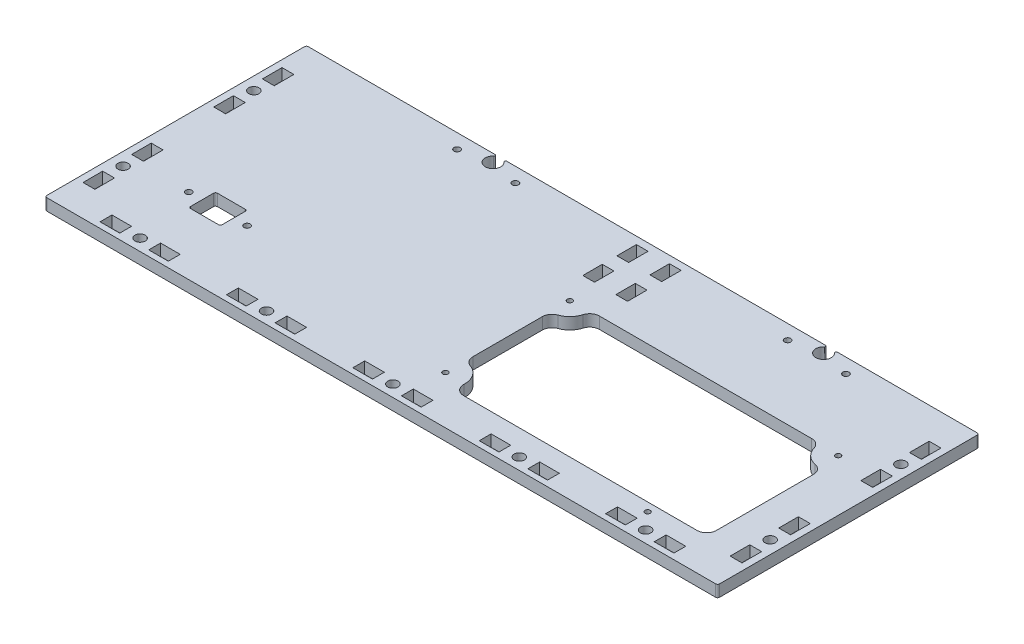
from build123d import *

# Parameters (mm, degrees)
SKETCH1_W                = 346
SKETCH1_H                = 134.5
BOSS_EXTRUDE1_DEPTH      = 6
M5_CLEARANCE_HOLE1_D     = 5.3
M5_CLEARANCE_HOLE2_D     = 5.3
SKETCH5_W                = 140
SKETCH5_H                = 70.4
CUT_EXTRUDE1_DEPTH       = 7
SKETCH6_R                = 10
BOSS_EXTRUDE2_DEPTH      = 6
FILLET1_R                = 5
M2_5_CLEARANCE_HOLE1_D   = 2.7
CUT_EXTRUDE29_DEPTH      = 7
SKETCH72_W               = 6.1
SKETCH72_H               = 10.1
CUT_EXTRUDE2_DEPTH       = 4
CUT_EXTRUDE2_DEPTH_BACK  = 4
SKETCH73_W               = 6.1
SKETCH73_H               = 10.1
CUT_EXTRUDE21_DEPTH      = 4
CUT_EXTRUDE21_DEPTH_BACK = 4
SKETCH74_W               = 6.1
SKETCH74_H               = 10.1
CUT_EXTRUDE22_DEPTH      = 4
CUT_EXTRUDE22_DEPTH_BACK = 4
SKETCH75_W               = 6.1
SKETCH75_H               = 10.1
CUT_EXTRUDE23_DEPTH      = 4
CUT_EXTRUDE23_DEPTH_BACK = 4
SKETCH76_W               = 6.1
SKETCH76_H               = 10.1
CUT_EXTRUDE24_DEPTH      = 4
CUT_EXTRUDE24_DEPTH_BACK = 4
SKETCH771_W              = 6.1
SKETCH771_H              = 10.1
CUT_EXTRUDE25_DEPTH      = 4
CUT_EXTRUDE25_DEPTH_BACK = 4
SKETCH781_W              = 6.1
SKETCH781_H              = 10.1
CUT_EXTRUDE26_DEPTH      = 4
CUT_EXTRUDE26_DEPTH_BACK = 4
SKETCH79_W               = 6.1
SKETCH79_H               = 10.1
CUT_EXTRUDE27_DEPTH      = 4
CUT_EXTRUDE27_DEPTH_BACK = 4
SKETCH710_W              = 6.1
SKETCH710_H              = 10.1
CUT_EXTRUDE28_DEPTH      = 4
CUT_EXTRUDE28_DEPTH_BACK = 4
SKETCH63_W               = 10
SKETCH63_H               = 6
CUT_EXTRUDE13_DEPTH      = 4
SKETCH64_W               = 10
SKETCH64_H               = 6
CUT_EXTRUDE14_DEPTH      = 4
M3_CLEARANCE_HOLE1_D     = 3.2
SKETCH786_W              = 16.25
SKETCH786_H              = 13.75
CUT_EXTRUDE30_DEPTH      = 7
M3_CLEARANCE_HOLE2_D     = 3.2
FILLET2_R                = 1
FILLET3_R                = 1


with BuildPart() as part:
    # Sketch1 → Boss-Extrude1 (new body)
    with BuildSketch(Plane(origin=(0, 0, 0), x_dir=(1, 0, 0), z_dir=(0, 1, 0))):
        Rectangle(SKETCH1_W, SKETCH1_H)
    extrude(amount=BOSS_EXTRUDE1_DEPTH)

    # M5 Clearance Hole1 (through all)
    with Locations(Plane(origin=(0, 6, 0), x_dir=(1, 0, 0), z_dir=(0, 1, 0))):
        with Locations((0, -61.25), (65, -61.25), (130, -61.25)):
            m5_clearance_hole1 = Hole(M5_CLEARANCE_HOLE1_D / 2)

    # Mirror1: M5 Clearance Hole1 across plane
    add(m5_clearance_hole1.mirror(Plane(origin=(0, 0, 0), x_dir=(0, 0, 1), z_dir=(1, 0, 0))), mode=Mode.SUBTRACT)

    # M5 Clearance Hole2 (through all)
    with Locations(Plane(origin=(0, 6, 0), x_dir=(1, 0, 0), z_dir=(0, 1, 0))):
        with Locations((166.4, -33.625), (166.4, 33.625)):
            m5_clearance_hole2 = Hole(M5_CLEARANCE_HOLE2_D / 2)

    # Mirror2: M5 Clearance Hole2 across plane
    add(m5_clearance_hole2.mirror(Plane(origin=(0, 0, 0), x_dir=(0, 0, 1), z_dir=(1, 0, 0))), mode=Mode.SUBTRACT)

    # Sketch5 → Cut-Extrude1 (cut, through all)
    with BuildSketch(Plane(origin=(0, 0, 0), x_dir=(-1, 0, 0), z_dir=(0, -1, 0))):
        with Locations((-78.4, -13.05)):
            Rectangle(SKETCH5_W, SKETCH5_H)
    extrude(amount=-CUT_EXTRUDE1_DEPTH, mode=Mode.SUBTRACT)

    # Sketch6 → Boss-Extrude2 (add)
    with BuildSketch(Plane.XZ):
        with Locations((8.4, -21.35)):
            Circle(SKETCH6_R)
        with Locations((8.4, 42.65)):
            Circle(SKETCH6_R)
        with Locations((146.4, -21.35)):
            Circle(SKETCH6_R)
    extrude(amount=-BOSS_EXTRUDE2_DEPTH)

    # Fillet1
    fillet1_edges = [part.edges().sort_by_distance(p)[0] for p in [
        (148.4, 3, -11.552041029),
        (148.4, 3, 48.25),
        (8.4, 3, -11.35),
        (18.367948636, 3, -22.15),
        (16.684926071, 3, 48.25),
        (8.4, 3, 32.65),
        (136.432051364, 3, -22.15),
    ]]
    fillet(fillet1_edges, radius=FILLET1_R)

    # M2.5 Clearance Hole1 (through all)
    with Locations(Plane(origin=(0, 6, 0), x_dir=(1, 0, 0), z_dir=(0, 1, 0))):
        with Locations((8.4, -42.65), (8.4, 21.35), (146.4, 21.35), (122.4, -52.65)):
            Hole(M2_5_CLEARANCE_HOLE1_D / 2)

    # Sketch783 → Cut-Extrude29 (cut, through all)
    with BuildSketch(Plane(origin=(0, 6, 0), x_dir=(1, 0, 0), z_dir=(0, 1, 0))):
        with BuildLine():
            Line((-76.023715784, 67.25), (-69.976284216, 67.25))
            ThreePointArc((-69.976284216, 67.25), (-70.5108067, 66.880601937), (-70.354248689, 66.25))
            ThreePointArc((-70.354248689, 66.25), (-73, 59.25), (-75.645751311, 66.25))
            ThreePointArc((-75.645751311, 66.25), (-75.4891933, 66.880601937), (-76.023715784, 67.25))
        make_face()
    cut_extrude29 = extrude(amount=-CUT_EXTRUDE29_DEPTH, mode=Mode.SUBTRACT)

    # Mirror4: Cut-Extrude29 across plane
    add(cut_extrude29.mirror(Plane.ZY.offset(-12)), mode=Mode.SUBTRACT)

    # Sketch72 → Cut-Extrude2 (cut, two sides)
    with BuildSketch(Plane(origin=(110, 3, 105.25), x_dir=(0, 0, -1), z_dir=(0, 1, 0))) as cut_extrude2_sk:
        with Locations((44, -32.5)):
            Rectangle(SKETCH72_W, SKETCH72_H)
        with Locations((44, -7.5)):
            Rectangle(SKETCH72_W, SKETCH72_H)
    extrude(amount=CUT_EXTRUDE2_DEPTH, mode=Mode.SUBTRACT)
    extrude(cut_extrude2_sk.sketch, amount=-CUT_EXTRUDE2_DEPTH_BACK, mode=Mode.SUBTRACT)

    # Sketch73 → Cut-Extrude21 (cut, two sides)
    with BuildSketch(Plane(origin=(45, 3, 105.25), x_dir=(0, 0, -1), z_dir=(0, 1, 0))) as cut_extrude21_sk:
        with Locations((44, -32.5)):
            Rectangle(SKETCH73_W, SKETCH73_H)
        with Locations((44, -7.5)):
            Rectangle(SKETCH73_W, SKETCH73_H)
    extrude(amount=CUT_EXTRUDE21_DEPTH, mode=Mode.SUBTRACT)
    extrude(cut_extrude21_sk.sketch, amount=-CUT_EXTRUDE21_DEPTH_BACK, mode=Mode.SUBTRACT)

    # Sketch74 → Cut-Extrude22 (cut, two sides)
    with BuildSketch(Plane(origin=(-20, 3, 105.25), x_dir=(0, 0, -1), z_dir=(0, 1, 0))) as cut_extrude22_sk:
        with Locations((44, -32.5)):
            Rectangle(SKETCH74_W, SKETCH74_H)
        with Locations((44, -7.5)):
            Rectangle(SKETCH74_W, SKETCH74_H)
    extrude(amount=CUT_EXTRUDE22_DEPTH, mode=Mode.SUBTRACT)
    extrude(cut_extrude22_sk.sketch, amount=-CUT_EXTRUDE22_DEPTH_BACK, mode=Mode.SUBTRACT)

    # Sketch75 → Cut-Extrude23 (cut, two sides)
    with BuildSketch(Plane(origin=(-85, 3, 105.25), x_dir=(0, 0, -1), z_dir=(0, 1, 0))) as cut_extrude23_sk:
        with Locations((44, -32.5)):
            Rectangle(SKETCH75_W, SKETCH75_H)
        with Locations((44, -7.5)):
            Rectangle(SKETCH75_W, SKETCH75_H)
    extrude(amount=CUT_EXTRUDE23_DEPTH, mode=Mode.SUBTRACT)
    extrude(cut_extrude23_sk.sketch, amount=-CUT_EXTRUDE23_DEPTH_BACK, mode=Mode.SUBTRACT)

    # Sketch76 → Cut-Extrude24 (cut, two sides)
    with BuildSketch(Plane(origin=(-150, 3, 105.25), x_dir=(0, 0, -1), z_dir=(0, 1, 0))) as cut_extrude24_sk:
        with Locations((44, -32.5)):
            Rectangle(SKETCH76_W, SKETCH76_H)
        with Locations((44, -7.5)):
            Rectangle(SKETCH76_W, SKETCH76_H)
    extrude(amount=CUT_EXTRUDE24_DEPTH, mode=Mode.SUBTRACT)
    extrude(cut_extrude24_sk.sketch, amount=-CUT_EXTRUDE24_DEPTH_BACK, mode=Mode.SUBTRACT)

    # Sketch771 → Cut-Extrude25 (cut, two sides)
    with BuildSketch(Plane(origin=(210.4, 3, 53.625), x_dir=(-1, 0, 0), z_dir=(0, 1, 0))) as cut_extrude25_sk:
        with Locations((44, -32.5)):
            Rectangle(SKETCH771_W, SKETCH771_H)
        with Locations((44, -7.5)):
            Rectangle(SKETCH771_W, SKETCH771_H)
    extrude(amount=CUT_EXTRUDE25_DEPTH, mode=Mode.SUBTRACT)
    extrude(cut_extrude25_sk.sketch, amount=-CUT_EXTRUDE25_DEPTH_BACK, mode=Mode.SUBTRACT)

    # Sketch781 → Cut-Extrude26 (cut, two sides)
    with BuildSketch(Plane(origin=(210.4, 3, -13.625), x_dir=(-1, 0, 0), z_dir=(0, 1, 0))) as cut_extrude26_sk:
        with Locations((44, -32.5)):
            Rectangle(SKETCH781_W, SKETCH781_H)
        with Locations((44, -7.5)):
            Rectangle(SKETCH781_W, SKETCH781_H)
    extrude(amount=CUT_EXTRUDE26_DEPTH, mode=Mode.SUBTRACT)
    extrude(cut_extrude26_sk.sketch, amount=-CUT_EXTRUDE26_DEPTH_BACK, mode=Mode.SUBTRACT)

    # Sketch79 → Cut-Extrude27 (cut, two sides)
    with BuildSketch(Plane(origin=(-122.4, 3, -13.625), x_dir=(-1, 0, 0), z_dir=(0, 1, 0))) as cut_extrude27_sk:
        with Locations((44, -32.5)):
            Rectangle(SKETCH79_W, SKETCH79_H)
        with Locations((44, -7.5)):
            Rectangle(SKETCH79_W, SKETCH79_H)
    extrude(amount=CUT_EXTRUDE27_DEPTH, mode=Mode.SUBTRACT)
    extrude(cut_extrude27_sk.sketch, amount=-CUT_EXTRUDE27_DEPTH_BACK, mode=Mode.SUBTRACT)

    # Sketch710 → Cut-Extrude28 (cut, two sides)
    with BuildSketch(Plane(origin=(-122.4, 3, 53.625), x_dir=(-1, 0, 0), z_dir=(0, 1, 0))) as cut_extrude28_sk:
        with Locations((44, -32.5)):
            Rectangle(SKETCH710_W, SKETCH710_H)
        with Locations((44, -7.5)):
            Rectangle(SKETCH710_W, SKETCH710_H)
    extrude(amount=CUT_EXTRUDE28_DEPTH, mode=Mode.SUBTRACT)
    extrude(cut_extrude28_sk.sketch, amount=-CUT_EXTRUDE28_DEPTH_BACK, mode=Mode.SUBTRACT)

    # Sketch63 → Cut-Extrude13 (cut, symmetric)
    with BuildSketch(Plane(origin=(47.5, 3, -59.242778608), x_dir=(0, 0, 1), z_dir=(0, 1, 0))):
        with Locations((0.767778608, -44)):
            Rectangle(SKETCH63_W, SKETCH63_H)
    cut_extrude13 = extrude(amount=CUT_EXTRUDE13_DEPTH, both=True, mode=Mode.SUBTRACT)

    # Sketch64 → Cut-Extrude14 (cut, symmetric)
    with BuildSketch(Plane(origin=(-40.5, 3, -40.157221392), x_dir=(0, 0, -1), z_dir=(0, 1, 0))):
        with Locations((0.767778608, -44)):
            Rectangle(SKETCH64_W, SKETCH64_H)
    cut_extrude14 = extrude(amount=CUT_EXTRUDE14_DEPTH, both=True, mode=Mode.SUBTRACT)

    # Mirror3: Cut-Extrude13, Cut-Extrude14 across plane
    add(cut_extrude13.mirror(Plane(origin=(12, 0, 0), x_dir=(0, 0, 1), z_dir=(1, 0, 0))), mode=Mode.SUBTRACT)
    add(cut_extrude14.mirror(Plane(origin=(12, 0, 0), x_dir=(0, 0, 1), z_dir=(1, 0, 0))), mode=Mode.SUBTRACT)

    # M3 Clearance Hole1 (through all)
    with Locations(Plane(origin=(0, 6, 0), x_dir=(1, 0, 0), z_dir=(0, 1, 0))):
        with Locations((-88, 59.75), (-58, 59.75), (82, 59.75), (112, 59.75)):
            Hole(M3_CLEARANCE_HOLE1_D / 2)

    # Sketch786 → Cut-Extrude30 (cut, through all)
    with BuildSketch(Plane.XZ):
        with Locations((-123, 28.25)):
            Rectangle(SKETCH786_W, SKETCH786_H)
    extrude(amount=-CUT_EXTRUDE30_DEPTH, mode=Mode.SUBTRACT)

    # M3 Clearance Hole2 (through all)
    with Locations(Plane(origin=(0, 0, 0), x_dir=(-1, 0, 0), z_dir=(0, -1, 0))):
        with Locations((108, -28.25), (138, -28.25)):
            Hole(M3_CLEARANCE_HOLE2_D / 2)

    # Fillet2
    fillet2_edges = [part.edges().sort_by_distance(p)[0] for p in [
        (-114.875, 3, 35.125),
        (-114.875, 3, 21.375),
        (-131.125, 3, 21.375),
        (-131.125, 3, 35.125),
    ]]
    fillet(fillet2_edges, radius=FILLET2_R)

    # Fillet3
    fillet3_edges = [part.edges().sort_by_distance(p)[0] for p in [
        (173, 3, 67.25),
        (-173, 3, 67.25),
        (-173, 3, -67.25),
        (173, 3, -67.25),
    ]]
    fillet(fillet3_edges, radius=FILLET3_R)


solid = part.part
